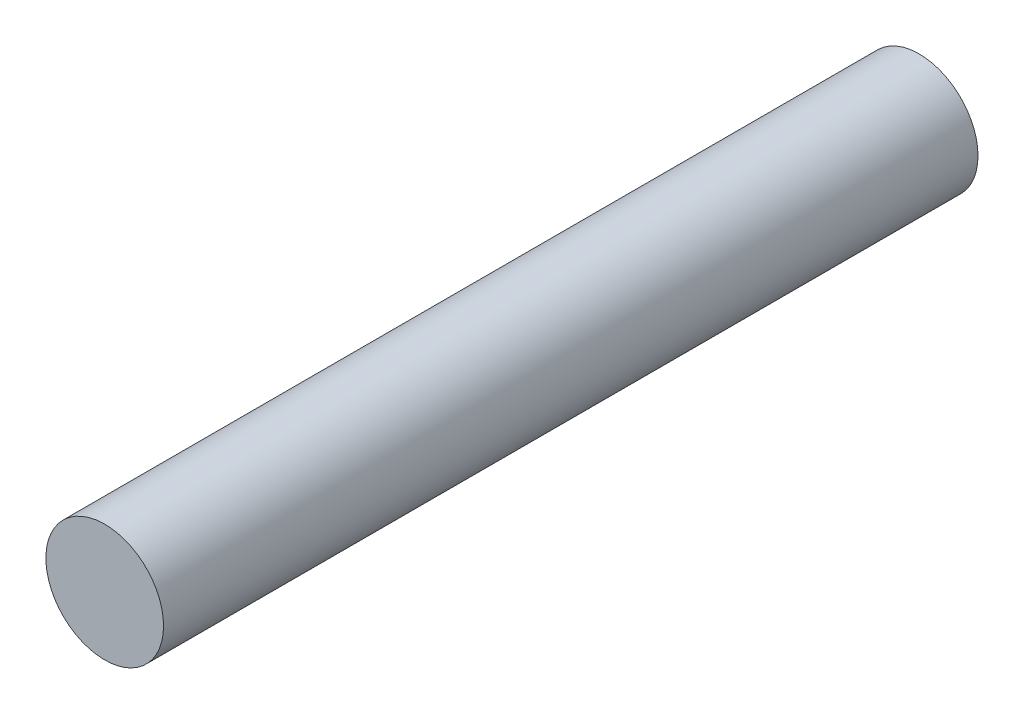
from build123d import *

# Parameters (mm, degrees)
SKETCH1_R           = 6.5
BOSS_EXTRUDE1_DEPTH = 45


with BuildPart() as part:
    # Sketch1 → Boss-Extrude1 (new body, symmetric)
    with BuildSketch(Plane.XY):
        Circle(SKETCH1_R)
    extrude(amount=BOSS_EXTRUDE1_DEPTH, both=True)


solid = part.part
